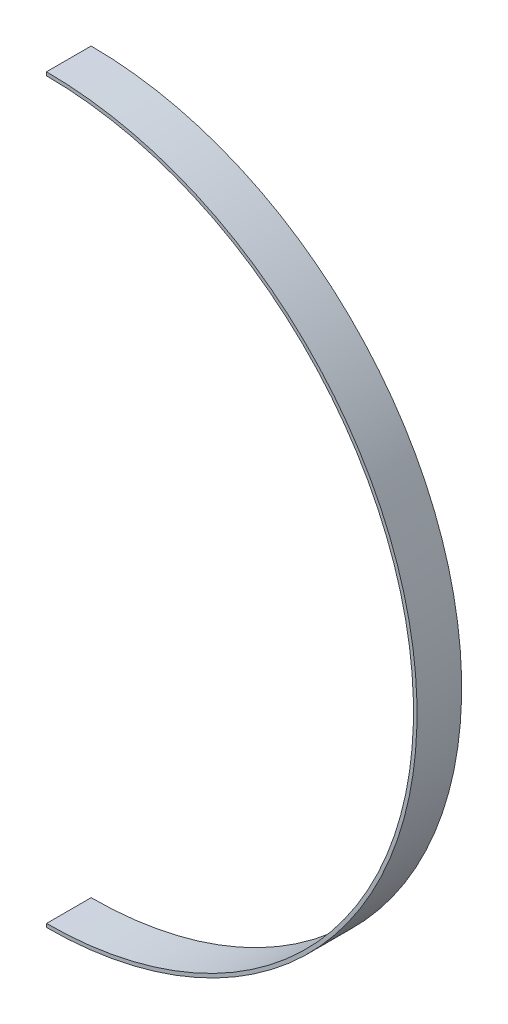
from build123d import *

# Parameters (mm, degrees)
BOSS_EXTRUDE1_DEPTH = 10


with BuildPart() as part:
    # Sketch1 → Boss-Extrude1 (new body)
    with BuildSketch(Plane.XY):
        with BuildLine():
            Line((0, 83.05), (0, 82.25625))
            ThreePointArc((0, 82.25625), (82.25625, 0), (0, -82.25625))
            Line((0, -82.25625), (0, -83.05))
            ThreePointArc((0, -83.05), (83.05, 0), (0, 83.05))
        make_face()
    extrude(amount=BOSS_EXTRUDE1_DEPTH)


solid = part.part
